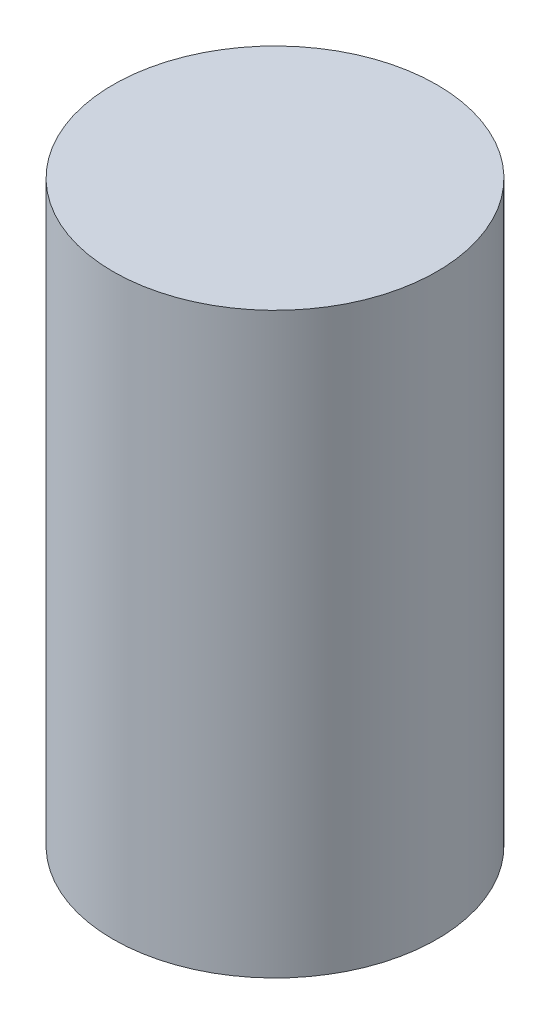
from build123d import *

# Parameters (mm, degrees)
SKETCH1_R           = 7
BOSS_EXTRUDE1_DEPTH = 25


with BuildPart() as part:
    # Sketch1 → Boss-Extrude1 (new body)
    with BuildSketch(Plane(origin=(0, 0, 0), x_dir=(1, 0, 0), z_dir=(0, 1, 0))):
        Circle(SKETCH1_R)
    extrude(amount=BOSS_EXTRUDE1_DEPTH)


solid = part.part
